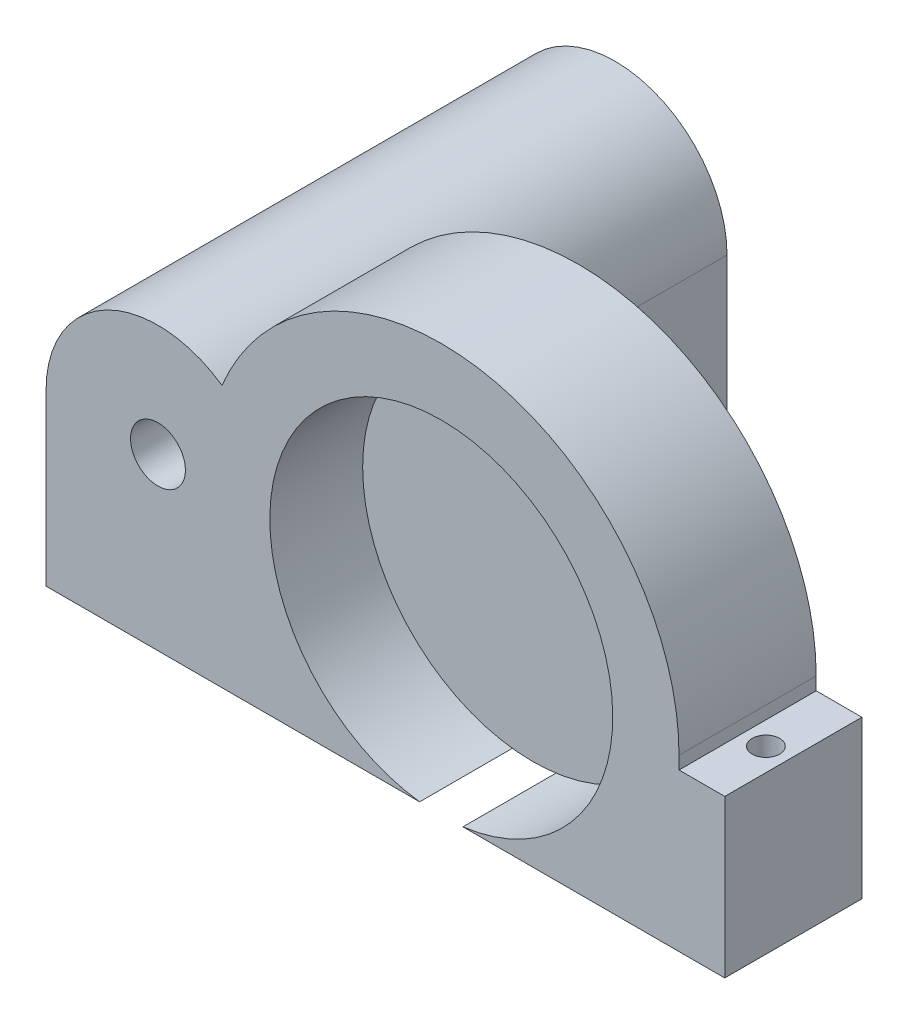
from build123d import *

# Parameters (mm, degrees)
BOSS_EXTRUDE1_DEPTH = 5
BOSS_EXTRUDE2_DEPTH = 15
SKETCH2_R           = 1.5
CUT_EXTRUDE1_DEPTH  = 20
BOSS_EXTRUDE3_START = -35
SKETCH3_R           = 3
BOSS_EXTRUDE3_DEPTH = 50


with BuildPart() as part:
    # Sketch1 → Boss-Extrude1 (new body)
    with BuildSketch(Plane.XY):
        with BuildLine():
            ThreePointArc((18.6, 0), (-13.152186141, 13.152186119), (3.1e-08, -18.6))
            ThreePointArc((3.1e-08, -18.6), (13.152186141, -13.152186119), (18.6, 0))
        make_face()
    extrude(amount=BOSS_EXTRUDE1_DEPTH)


with BuildPart() as body_2:
    # Sketch1_3 → Boss-Extrude2 (new body)
    with BuildSketch(Plane.XY):
        with BuildLine():
            ThreePointArc((26, 0), (0, 26), (-26, 0))
            Line((-26, 0), (-26, -1.40113329))
            Line((-26, -1.40113329), (-26, -18.6))
            Line((-26, -18.6), (-2.366960076, -18.6))
            ThreePointArc((-2.366960076, -18.6), (-12.393183582, 14.070234565), (18.75, 0))
            ThreePointArc((18.75, 0), (14.070234565, -12.393183582), (2.366960076, -18.6))
            Line((2.366960076, -18.6), (31, -18.6))
            Line((31, -18.6), (31, -1.40113329))
            Line((31, -1.40113329), (26, -1.40113329))
            Line((26, -1.40113329), (26, 0))
        make_face()
    extrude(amount=BOSS_EXTRUDE2_DEPTH)

    # Sketch2 → Cut-Extrude1 (cut)
    with BuildSketch(Plane(origin=(0, 0, 0), x_dir=(1, 0, 0), z_dir=(0, 1, 0))):
        with Locations((-28.5, -8)):
            Circle(SKETCH2_R)
        with Locations((28.5, -8)):
            Circle(SKETCH2_R)
    extrude(amount=-CUT_EXTRUDE1_DEPTH, mode=Mode.SUBTRACT)

    # Sketch3 → Boss-Extrude3 (add)
    with BuildSketch(Plane.XY.offset(BOSS_EXTRUDE3_START)):
        with BuildLine():
            ThreePointArc((-18.75, 0), (-30.984795994, 12.234795994), (-43.219591988, 0))
            Line((-43.219591988, 0), (-43.219591988, -18.6))
            Line((-43.219591988, -18.6), (-24.525129365, -18.6))
            Line((-24.525129365, -18.6), (-18.75, -18.6))
            Line((-18.75, -18.6), (-18.75, 0))
        make_face()
        with Locations((-30.984795994, 0)):
            Circle(SKETCH3_R, mode=Mode.SUBTRACT)
    extrude(amount=BOSS_EXTRUDE3_DEPTH)


solid = Compound([part.part, body_2.part])
